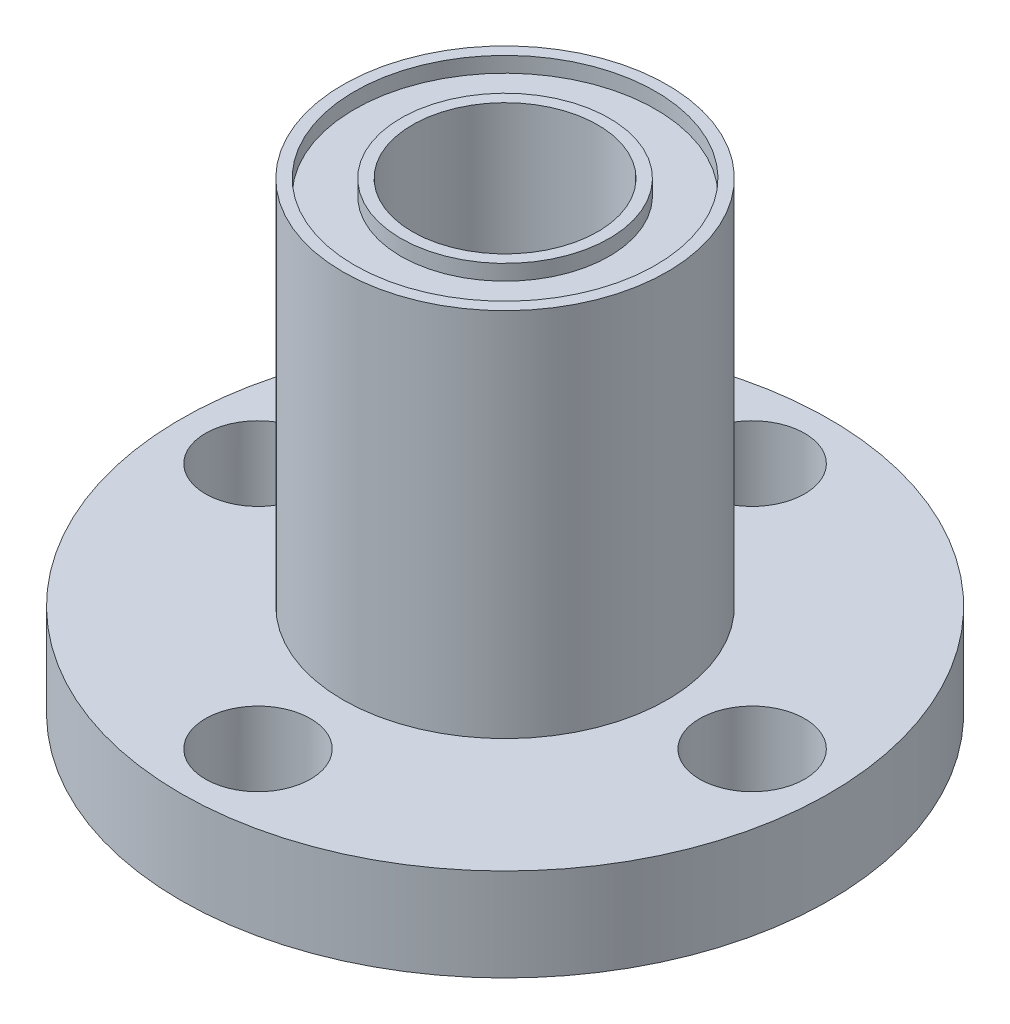
from build123d import *

# Parameters (mm, degrees)
SKETCH1_R           = 21
SKETCH1_R_2         = 6
BOSS_EXTRUDE1_DEPTH = 6
SKETCH2_R           = 10.5
SKETCH2_R_2         = 6
BOSS_EXTRUDE2_DEPTH = 24
SKETCH3_R           = 9.75
SKETCH3_R_2         = 6.75
CUT_EXTRUDE1_DEPTH  = 1
CUT_EXTRUDE2_START  = -7
SKETCH4_R           = 3.4
CUT_EXTRUDE2_DEPTH  = 32
CIRPATTERN1_COUNT   = 4


with BuildPart() as part:
    # Sketch1 → Boss-Extrude1 (new body)
    with BuildSketch(Plane(origin=(0, 0, 0), x_dir=(1, 0, 0), z_dir=(0, 1, 0))):
        Circle(SKETCH1_R)
        Circle(SKETCH1_R_2, mode=Mode.SUBTRACT)
    extrude(amount=BOSS_EXTRUDE1_DEPTH)

    # Sketch2 → Boss-Extrude2 (add)
    with BuildSketch(Plane(origin=(0, 6, 0), x_dir=(1, 0, 0), z_dir=(0, 1, 0))):
        Circle(SKETCH2_R)
        Circle(SKETCH2_R_2, mode=Mode.SUBTRACT)
    extrude(amount=BOSS_EXTRUDE2_DEPTH)

    # Sketch3 → Cut-Extrude1 (cut)
    with BuildSketch(Plane(origin=(0, 30, 0), x_dir=(1, 0, 0), z_dir=(0, 1, 0))):
        Circle(SKETCH3_R)
        Circle(SKETCH3_R_2, mode=Mode.SUBTRACT)
    extrude(amount=-CUT_EXTRUDE1_DEPTH, mode=Mode.SUBTRACT)

    # Sketch4 → Cut-Extrude2 (cut)
    with BuildSketch(Plane(origin=(0, 6, 0), x_dir=(1, 0, 0), z_dir=(0, 1, 0)).offset(CUT_EXTRUDE2_START)):
        with Locations((16, 0)):
            Circle(SKETCH4_R)
    cut_extrude2 = extrude(amount=CUT_EXTRUDE2_DEPTH, mode=Mode.SUBTRACT)

    # CirPattern1: Cut-Extrude2 ×4 about axis
    cirpattern1_axis = Axis((0, 0, 0), (0, 1, 0))
    for i in range(1, CIRPATTERN1_COUNT):
        add(cut_extrude2.rotate(cirpattern1_axis, i * 360 / CIRPATTERN1_COUNT), mode=Mode.SUBTRACT)


solid = part.part
